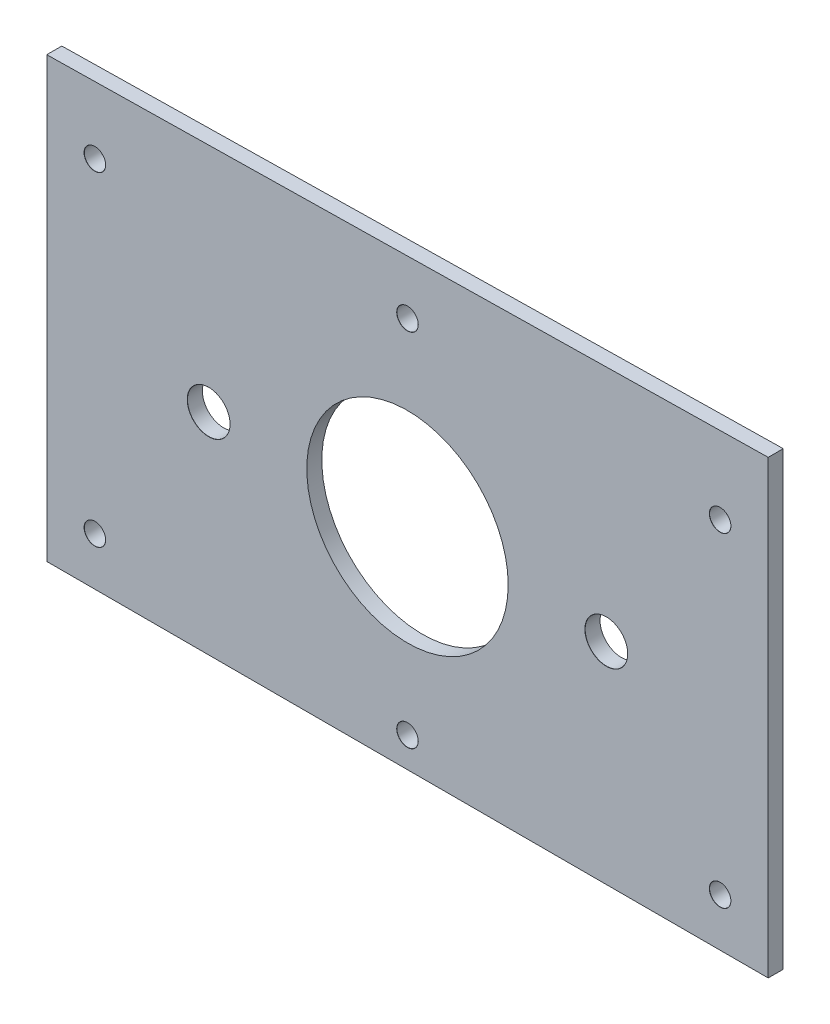
from build123d import *

# Parameters (mm, degrees)
BOSS_EXTRUDE1_DEPTH            = 3.175
M4_CLEARANCE_HOLE1_D           = 4.5
M4_CLEARANCE_HOLE1_CSINK_D     = 4.55
M4_CLEARANCE_HOLE1_CSINK_ANGLE = 90
M8_CLEARANCE_HOLE1_AT_2_COUNT  = 2
M8_CLEARANCE_HOLE1_AT_2_PITCH  = 84
SKETCH9_R                      = 21.275
CENTER_HOLE_DEPTH              = 4.175


with BuildPart() as part:
    # Sketch1 → Boss-Extrude1 (new body)
    with BuildSketch(Plane.XY):
        Polygon((-76.2, 48.26), (-76.2, 44.45), (-76.2, -44.45), (76.2, -44.45), (76.2, 44.45), (76.2, 50.8), align=None)
    extrude(amount=BOSS_EXTRUDE1_DEPTH)

    # M4 Clearance Hole1 (through all)
    with Locations(Plane.XY.offset(3.175)):
        with Locations((0, 38.1), (-66.04, 34.29), (-66.04, -34.29), (0, -38.1), (66.04, -34.29), (66.04, 34.29)):
            CounterSinkHole(M4_CLEARANCE_HOLE1_D / 2, M4_CLEARANCE_HOLE1_CSINK_D / 2, counter_sink_angle=M4_CLEARANCE_HOLE1_CSINK_ANGLE)

    # Sketch11 → M8 Clearance Hole1 (revolve, cut)
    with BuildSketch(Plane(origin=(-42, 0, 3.175), x_dir=(0, -1, 0), z_dir=(1, 0, 0))):
        Polygon((0, 0), (0, 3.175), (4.5, 3.175), (4.5, 0.025), (4.525, 0), align=None)
    m8_clearance_hole1 = revolve(axis=Axis((-42, 0, 9.525), (0, 0, -1)), mode=Mode.SUBTRACT)

    # M8 Clearance Hole1 at 2: M8 Clearance Hole1 ×2
    with Locations(*[(i * M8_CLEARANCE_HOLE1_AT_2_PITCH, 0, 0) for i in range(1, M8_CLEARANCE_HOLE1_AT_2_COUNT)]):
        add(m8_clearance_hole1, mode=Mode.SUBTRACT)

    # Sketch9 → Center Hole (cut, through all)
    with BuildSketch(Plane.XY.offset(3.175)):
        Circle(SKETCH9_R)
    extrude(amount=-CENTER_HOLE_DEPTH, mode=Mode.SUBTRACT)


solid = part.part
